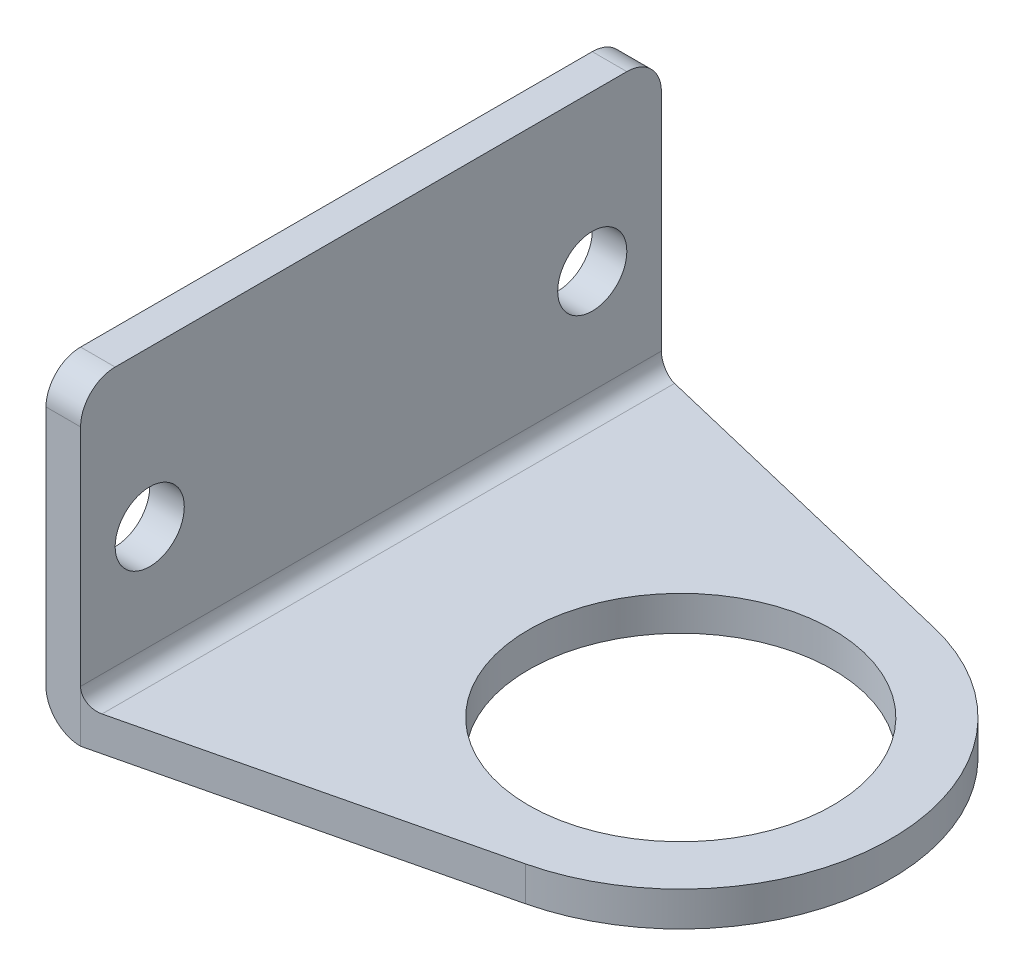
from build123d import *

# Parameters (mm, degrees)
SKETCH1_R           = 13.97
BOSS_EXTRUDE1_DEPTH = 3.175
SKETCH2_W           = 3.175
SKETCH2_H           = 53.34
BOSS_EXTRUDE2_DEPTH = 25.4
CUT_EXTRUDE1_DEPTH  = 51.927
FILLET1_R           = 1.5875
FILLET2_R           = 3.175
FILLET3_R           = 3.175


with BuildPart() as part:
    # Sketch1 → Boss-Extrude1 (new body)
    with BuildSketch(Plane(origin=(0, 0, 0), x_dir=(1, 0, 0), z_dir=(0, 1, 0))):
        with BuildLine():
            ThreePointArc((4.499810369, -18.772216775), (19.304, 0), (4.499810369, 18.772216775))
            Line((4.499810369, 18.772216775), (-28.448, 26.67))
            Line((-28.448, 26.67), (-31.623, 26.67))
            Line((-31.623, 26.67), (-31.623, -26.67))
            Line((-31.623, -26.67), (-28.448, -26.67))
            Line((-28.448, -26.67), (4.499810369, -18.772216775))
        make_face()
        Circle(SKETCH1_R, mode=Mode.SUBTRACT)
    extrude(amount=BOSS_EXTRUDE1_DEPTH)

    # Sketch2 → Boss-Extrude2 (add)
    with BuildSketch(Plane(origin=(0, 3.175, 0), x_dir=(1, 0, 0), z_dir=(0, 1, 0))):
        with Locations((-30.0355, 0)):
            Rectangle(SKETCH2_W, SKETCH2_H)
    extrude(amount=BOSS_EXTRUDE2_DEPTH)

    # Sketch6 → Cut-Extrude1 (cut, through all)
    with BuildSketch(Plane.ZY.offset(31.623)):
        with BuildLine():
            Line((-20.32, 11.1125), (-20.32, 14.2875))
            Line((-20.32, 14.2875), (-20.32, 17.4625))
            ThreePointArc((-20.32, 17.4625), (-23.495, 14.2875), (-20.32, 11.1125))
        make_face()
        with BuildLine():
            ThreePointArc((-20.32, 11.1125), (-18.07493597, 12.04243597), (-17.145, 14.2875))
            Line((-17.145, 14.2875), (-20.32, 14.2875))
            Line((-20.32, 14.2875), (-20.32, 11.1125))
        make_face()
        with BuildLine():
            Line((-20.32, 14.2875), (-17.145, 14.2875))
            ThreePointArc((-17.145, 14.2875), (-18.07493597, 16.53256403), (-20.32, 17.4625))
            Line((-20.32, 17.4625), (-20.32, 14.2875))
        make_face()
        with BuildLine():
            ThreePointArc((23.495, 14.2875), (20.32, 17.4625), (17.145, 14.2875))
            Line((17.145, 14.2875), (20.32, 14.2875))
            Line((20.32, 14.2875), (23.495, 14.2875))
        make_face()
        with BuildLine():
            Line((20.32, 14.2875), (17.145, 14.2875))
            ThreePointArc((17.145, 14.2875), (20.32, 11.1125), (23.495, 14.2875))
            Line((23.495, 14.2875), (20.32, 14.2875))
        make_face()
    extrude(amount=-CUT_EXTRUDE1_DEPTH, mode=Mode.SUBTRACT)

    # Fillet1
    fillet1_edges = [part.edges().sort_by_distance(p)[0] for p in [
        (-28.448, 3.175, 0),
    ]]
    fillet(fillet1_edges, radius=FILLET1_R)

    # Fillet2
    fillet2_edges = [part.edges().sort_by_distance(p)[0] for p in [
        (-31.623, 0, 0),
    ]]
    fillet(fillet2_edges, radius=FILLET2_R)

    # Fillet3
    fillet3_edges = [part.edges().sort_by_distance(p)[0] for p in [
        (-30.0355, 28.575, -26.67),
        (-30.0355, 28.575, 26.67),
    ]]
    fillet(fillet3_edges, radius=FILLET3_R)


solid = part.part
